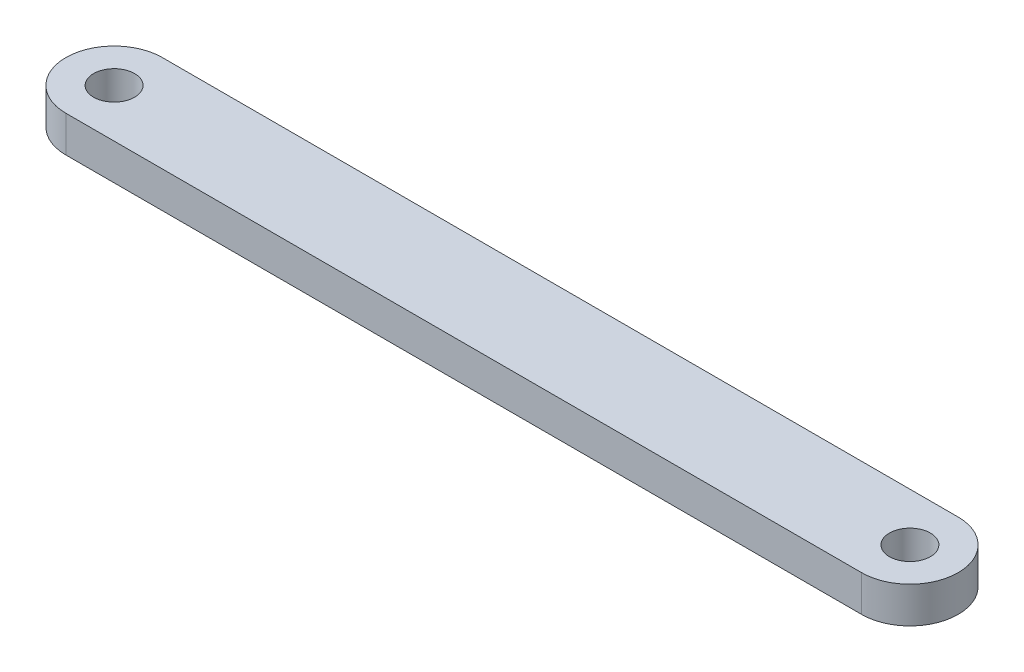
from build123d import *

# Parameters (mm, degrees)
SKETCH_1_R      = 1.7
EXTRUDE_1_DEPTH = 3


with BuildPart() as part:
    # 草图1 → 凸台-拉伸1 (new body)
    with BuildSketch(Plane(origin=(0, 0, 0), x_dir=(1, 0, 0), z_dir=(0, 1, 0))):
        with BuildLine():
            Line((-33, 4), (33, 4))
            ThreePointArc((33, 4), (37, 0), (33, -4))
            Line((33, -4), (-33, -4))
            ThreePointArc((-33, -4), (-37, 0), (-33, 4))
        make_face()
        with Locations((-33, 0)):
            Circle(SKETCH_1_R, mode=Mode.SUBTRACT)
        with Locations((33, 0)):
            Circle(SKETCH_1_R, mode=Mode.SUBTRACT)
    extrude(amount=EXTRUDE_1_DEPTH)


solid = part.part
